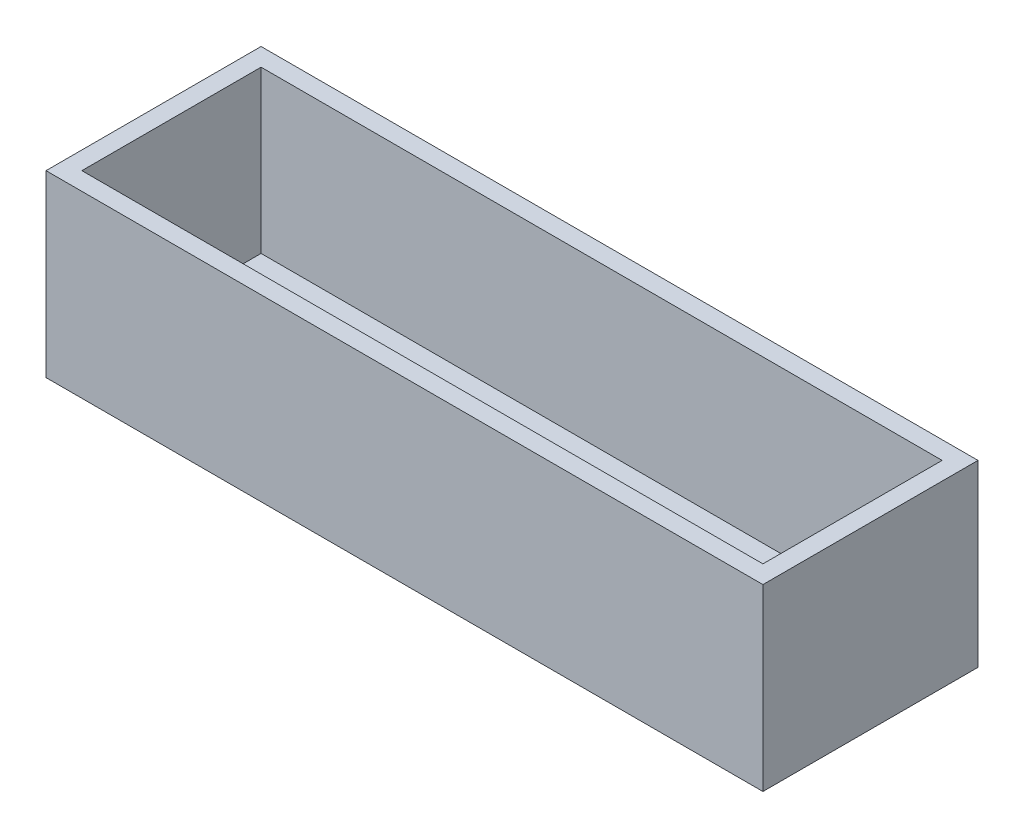
from build123d import *

# Parameters (mm, degrees)
SKETCH1_W           = 200
SKETCH1_H           = 60
BOSS_EXTRUDE1_DEPTH = 50
SHELL1_T            = -5


with BuildPart() as part:
    # Sketch1 → Boss-Extrude1 (new body)
    with BuildSketch(Plane(origin=(0, 0, 0), x_dir=(1, 0, 0), z_dir=(0, 1, 0))):
        with Locations((100, 30)):
            Rectangle(SKETCH1_W, SKETCH1_H)
    extrude(amount=BOSS_EXTRUDE1_DEPTH)

    # Shell1
    shell1_openings = [part.faces().sort_by_distance(p)[0] for p in [
        (100, 50, -30),
    ]]
    offset(amount=SHELL1_T, openings=shell1_openings, kind=Kind.INTERSECTION)


solid = part.part
